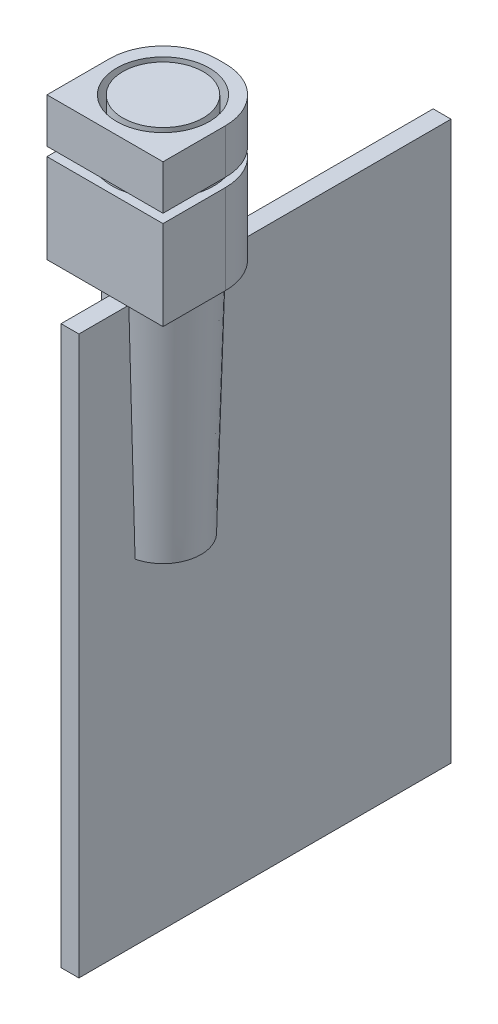
from build123d import *

# Parameters (mm, degrees)
SKETCH_8_R       = 450
EXTRUDE_3_DEPTH  = 500
SKETCH_20_R      = 425
SKETCH_22_W      = 4170
SKETCH_22_H      = 6250
EXTRUDE_9_DEPTH  = 100
SKETCH_23_W      = 1300
SKETCH_23_H      = 1300
SKETCH_23_R      = 520
EXTRUDE_10_DEPTH = 500
SKETCH_24_W      = 1300
SKETCH_24_H      = 1300
SKETCH_24_R      = 570
EXTRUDE_11_DEPTH = 1000
FILLET_1_R       = 600
FILLET_2_R       = 600


with BuildPart() as part:
    # 草图8 → 凸台-拉伸3 (new body)
    with BuildSketch(Plane(origin=(0, 0, 0), x_dir=(1, 0, 0), z_dir=(0, 1, 0))):
        with Locations(Location((0, 0, 0), (0, 0, 270))):
            Circle(SKETCH_8_R)
    extrude(amount=-EXTRUDE_3_DEPTH)

    # 草图19 → 旋转1 (revolve)
    with BuildSketch(Plane(origin=(0, 0, 0), x_dir=(0, 0, -1), z_dir=(1, 0, 0))):
        Polygon((450, -500), (500, -600), (500, -1500), (0, -1500), (0, -500), align=None)
    revolve(axis=Axis((0, -1500, 0), (0, 1, 0)))

    # 草图20 → section 1 of loft_2
    with BuildSketch(Plane(origin=(0, -4250, 0), x_dir=(-1, 0, 0), z_dir=(0, -1, 0)), mode=Mode.PRIVATE) as loft_2_s1:
        Circle(SKETCH_20_R)
    # loft up to a face of the part (loft_2)
    loft([Face(Wire([part.edges().sort_by_distance((364.484313711, -1500, 342.273552964))[0]])), loft_2_s1.sketch])

    # 草图22 → 凸台-拉伸9 (add, symmetric)
    with BuildSketch(Plane(origin=(0, 0, 0), x_dir=(0, 0, -1), z_dir=(1, 0, 0))):
        with Locations((1042.5, -4875)):
            Rectangle(SKETCH_22_W, SKETCH_22_H)
    extrude(amount=EXTRUDE_9_DEPTH, both=True)


with BuildPart() as body_2:
    # 草图23 → 凸台-拉伸10 (new body)
    with BuildSketch(Plane(origin=(0, 0, 0), x_dir=(1, 0, 0), z_dir=(0, 1, 0))):
        Rectangle(SKETCH_23_W, SKETCH_23_H)
        with Locations(Location((0, 0, 0), (0, 0, 270))):
            Circle(SKETCH_23_R, mode=Mode.SUBTRACT)
    extrude(amount=-EXTRUDE_10_DEPTH)

    # 圆角1
    fillet_1_edges = [body_2.edges().sort_by_distance(p)[0] for p in [
        (-650, -250, -650),
        (650, -250, -650),
    ]]
    fillet(fillet_1_edges, radius=FILLET_1_R)


with BuildPart() as body_3:
    # 草图24 → 凸台-拉伸11 (new body)
    with BuildSketch(Plane(origin=(0, -600, 0), x_dir=(1, 0, 0), z_dir=(0, 1, 0))):
        Rectangle(SKETCH_24_W, SKETCH_24_H)
        with Locations(Location((0, 0, 0), (0, 0, 270))):
            Circle(SKETCH_24_R, mode=Mode.SUBTRACT)
    extrude(amount=-EXTRUDE_11_DEPTH)

    # 圆角2
    fillet_2_edges = [body_3.edges().sort_by_distance(p)[0] for p in [
        (-650, -1100, -650),
        (650, -1100, -650),
    ]]
    fillet(fillet_2_edges, radius=FILLET_2_R)


solid = Compound([part.part, body_2.part, body_3.part])
